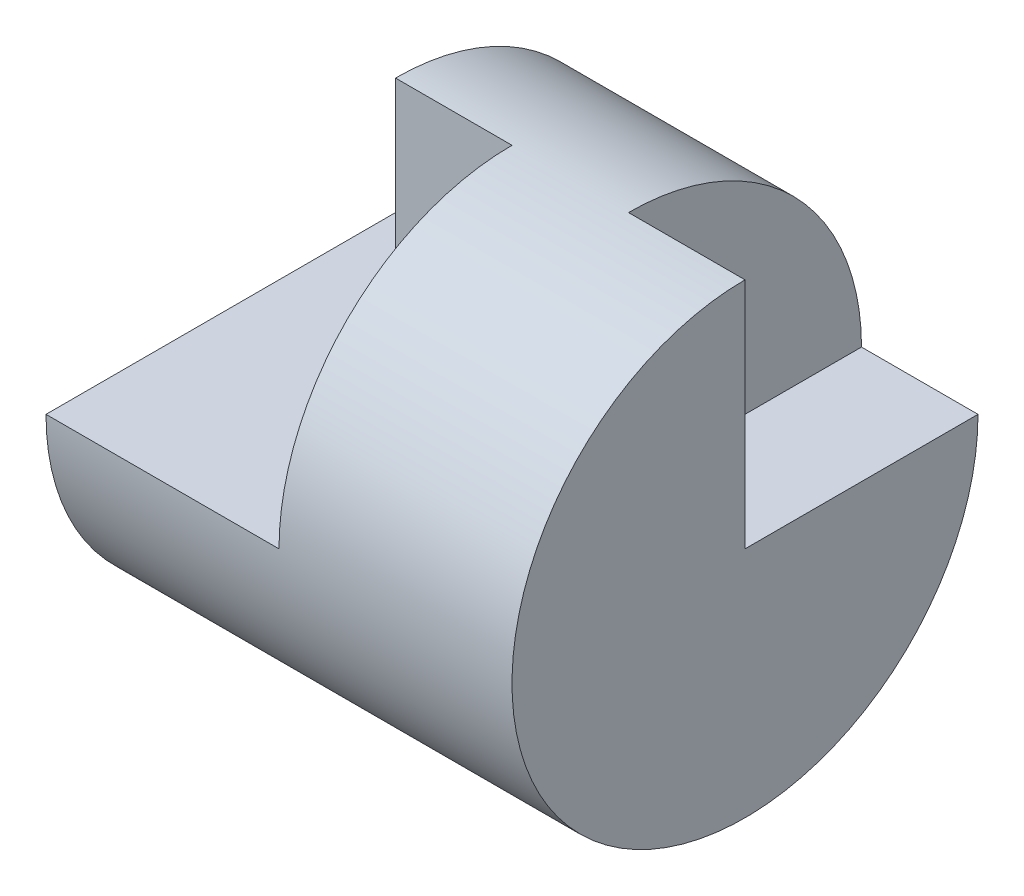
from build123d import *

# Parameters (mm, degrees)
SKETCH5_W          = 4
SKETCH5_H          = 2
SKETCH6_W          = 1
SKETCH6_H          = 2
CUT_EXTRUDE5_DEPTH = 11
SKETCH8_W          = 0.5
SKETCH8_H          = 2
CUT_EXTRUDE7_DEPTH = 10
SKETCH9_W          = 1.5
SKETCH9_H          = 2
CUT_EXTRUDE8_DEPTH = 10


with BuildPart() as part:
    # Sketch5 → Revolve-Thin2 (revolve)
    with BuildSketch(Plane.XY):
        with Locations((2, 1)):
            Rectangle(SKETCH5_W, SKETCH5_H)
    revolve(axis=Axis((0, 0, 0), (1, 0, 0)))

    # Sketch6 → Cut-Extrude5 (cut)
    with BuildSketch(Plane.XY):
        with Locations((3.5, 1)):
            Rectangle(SKETCH6_W, SKETCH6_H)
        with Locations((0.5, 1)):
            Rectangle(SKETCH6_W, SKETCH6_H)
    extrude(amount=-CUT_EXTRUDE5_DEPTH, mode=Mode.SUBTRACT)

    # Sketch8 → Cut-Extrude7 (cut)
    with BuildSketch(Plane(origin=(0, 0, 0), x_dir=(-1, 0, 0), z_dir=(0, 0, -1))):
        with Locations((-0.25, 1)):
            Rectangle(SKETCH8_W, SKETCH8_H)
    extrude(amount=-CUT_EXTRUDE7_DEPTH, mode=Mode.SUBTRACT)

    # Sketch9 → Cut-Extrude8 (cut)
    with BuildSketch(Plane(origin=(0, 0, 0), x_dir=(-1, 0, 0), z_dir=(0, 0, -1))):
        with Locations((-1.25, 1)):
            Rectangle(SKETCH9_W, SKETCH9_H)
    extrude(amount=-CUT_EXTRUDE8_DEPTH, mode=Mode.SUBTRACT)


solid = part.part
